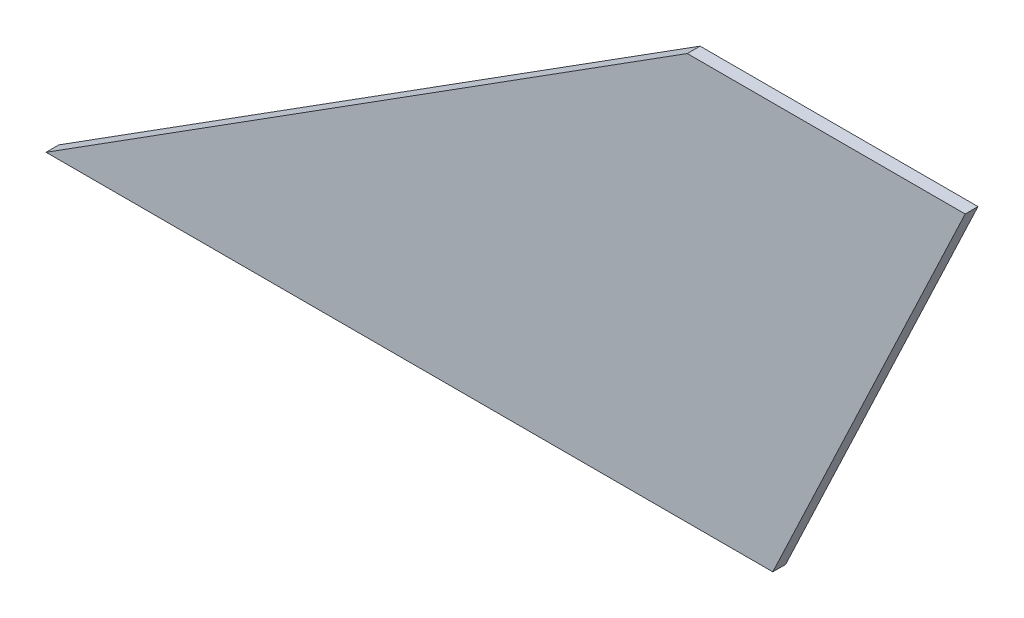
from build123d import *

# Parameters (mm, degrees)
BOSS_EXTRUDE1_DEPTH = 3


with BuildPart() as part:
    # Sketch1 → Boss-Extrude1 (new body)
    with BuildSketch(Plane.XY):
        Polygon((0, 0), (170, 0), (215, 95), (150, 95), align=None)
    extrude(amount=BOSS_EXTRUDE1_DEPTH)


solid = part.part
